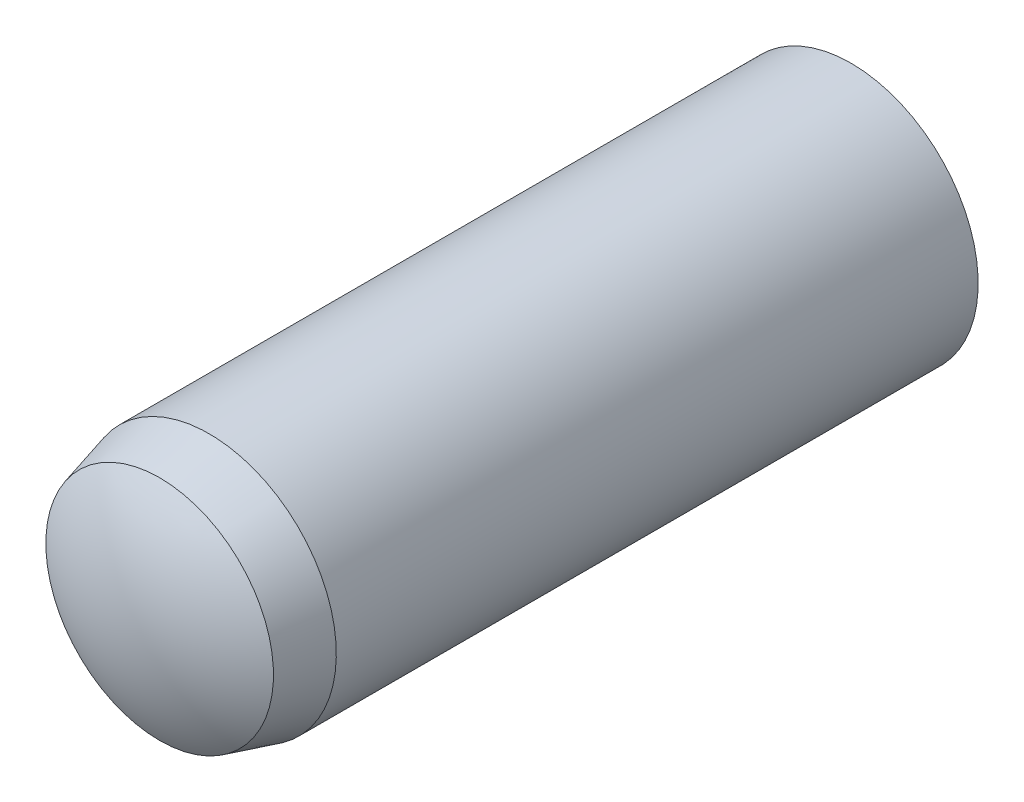
from build123d import *


with BuildPart() as part:
    # Sketch3 → Revolve1 (revolve)
    with BuildSketch(Plane(origin=(0, 0, 0), x_dir=(0, 0, -1), z_dir=(1, 0, 0))):
        with BuildLine():
            Line((-6, 0), (6, 0))
            ThreePointArc((6, 0), (5.846768836, 1.044030651), (5.4, 2))
            Line((5.4, 2), (-4.7, 2))
            Line((-4.7, 2), (-5.48, 1.79099963))
            ThreePointArc((-5.48, 1.79099963), (-5.867370053, 0.932480519), (-6, 0))
        make_face()
    revolve(axis=Axis((0, 0, 6), (0, 0, -1)))


solid = part.part
